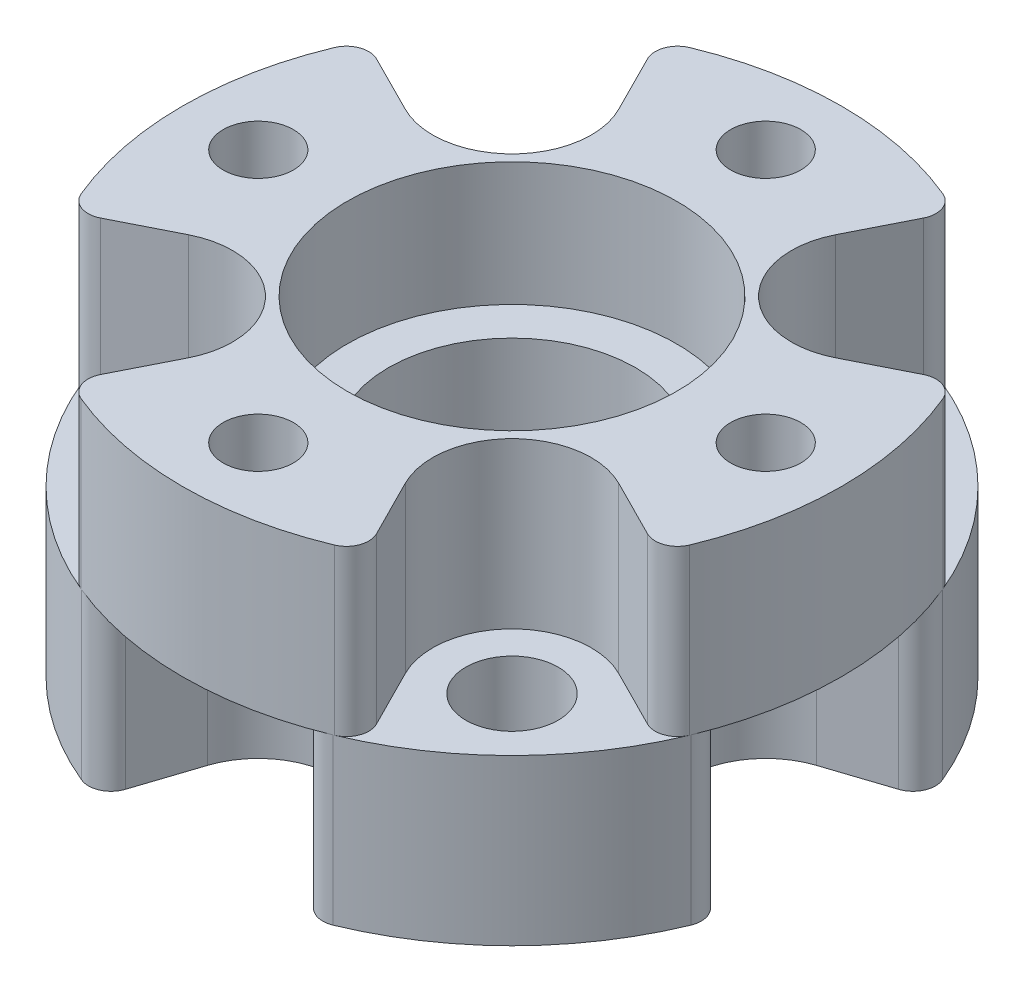
from build123d import *

# Parameters (mm, degrees)
SKETCH1_W                  = 12.7
SKETCH1_H                  = 12.7
CUT_EXTRUDE1_DEPTH         = 6.35
CUT_EXTRUDE2_DEPTH         = 6.35
CUT_EXTRUDE3_DEPTH         = 6.35
CUT_EXTRUDE4_DEPTH         = 6.35
CUT_EXTRUDE5_DEPTH         = 6.35
CUT_EXTRUDE6_DEPTH         = 6.35
CUT_EXTRUDE7_DEPTH         = 6.35
CUT_EXTRUDE8_DEPTH         = 6.35
M3_CLEARANCE_HOLE1_D       = 3.556
M3_CLEARANCE_HOLE1_DEPTH   = 6.35
M2_5_CLEARANCE_HOLE1_D     = 2.7051
M2_5_CLEARANCE_HOLE1_DEPTH = 6.35
FILLET1_R                  = 0.8636


with BuildPart() as part:
    # Sketch1 → Revolve1 (revolve)
    with BuildSketch(Plane.XY):
        with Locations((6.35, 6.35)):
            Rectangle(SKETCH1_W, SKETCH1_H)
    revolve(axis=Axis((0, 12.7, 0), (0, -1, 0)))

    # Sketch2 → Cut-Extrude1 (cut)
    with BuildSketch(Plane(origin=(0, 12.7, 0), x_dir=(-1, 0, 0), z_dir=(0, 1, 0))):
        with BuildLine():
            Line((-5.719139865, -11.339375609), (-4.182577123, -8.292822721))
            ThreePointArc((-4.182577123, -8.292822721), (-4.751006452, -4.751006452), (-8.292822721, -4.182577123))
            Line((-8.292822721, -4.182577123), (-11.339375609, -5.719139865))
            ThreePointArc((-11.339375609, -5.719139865), (-8.980256121, -8.980256121), (-5.719139865, -11.339375609))
        make_face()
    extrude(amount=-CUT_EXTRUDE1_DEPTH, mode=Mode.SUBTRACT)

    # Sketch3 → Cut-Extrude2 (cut)
    with BuildSketch(Plane(origin=(0, 12.7, 0), x_dir=(-1, 0, 0), z_dir=(0, 1, 0))):
        with BuildLine():
            Line((-11.339375609, 5.719139865), (-8.292822721, 4.182577123))
            ThreePointArc((-8.292822721, 4.182577123), (-4.751006452, 4.751006452), (-4.182577123, 8.292822721))
            Line((-4.182577123, 8.292822721), (-5.719139865, 11.339375609))
            ThreePointArc((-5.719139865, 11.339375609), (-8.980256121, 8.980256121), (-11.339375609, 5.719139865))
        make_face()
    extrude(amount=-CUT_EXTRUDE2_DEPTH, mode=Mode.SUBTRACT)

    # Sketch4 → Cut-Extrude3 (cut)
    with BuildSketch(Plane.XZ):
        with BuildLine():
            Line((12.062191969, 3.974106807), (8.821439828, 2.906382535))
            ThreePointArc((8.821439828, 2.906382535), (6.718937759, 0), (8.821439828, -2.906382535))
            Line((8.821439828, -2.906382535), (12.062191969, -3.974106807))
            ThreePointArc((12.062191969, -3.974106807), (12.7, 0), (12.062191969, 3.974106807))
        make_face()
    extrude(amount=-CUT_EXTRUDE3_DEPTH, mode=Mode.SUBTRACT)

    # Sketch5 → Cut-Extrude4 (cut)
    with BuildSketch(Plane(origin=(0, 12.7, 0), x_dir=(-1, 0, 0), z_dir=(0, 1, 0))):
        with BuildLine():
            Line((5.719139865, 11.339375609), (4.182577123, 8.292822721))
            ThreePointArc((4.182577123, 8.292822721), (4.751006452, 4.751006452), (8.292822721, 4.182577123))
            Line((8.292822721, 4.182577123), (11.339375609, 5.719139865))
            ThreePointArc((11.339375609, 5.719139865), (8.980256121, 8.980256121), (5.719139865, 11.339375609))
        make_face()
    extrude(amount=-CUT_EXTRUDE4_DEPTH, mode=Mode.SUBTRACT)

    # Sketch6 → Cut-Extrude5 (cut)
    with BuildSketch(Plane(origin=(0, 12.7, 0), x_dir=(-1, 0, 0), z_dir=(0, 1, 0))):
        with BuildLine():
            Line((11.339375609, -5.719139865), (8.292822721, -4.182577123))
            ThreePointArc((8.292822721, -4.182577123), (4.751006452, -4.751006452), (4.182577123, -8.292822721))
            Line((4.182577123, -8.292822721), (5.719139865, -11.339375609))
            ThreePointArc((5.719139865, -11.339375609), (8.980256121, -8.980256121), (11.339375609, -5.719139865))
        make_face()
    extrude(amount=-CUT_EXTRUDE5_DEPTH, mode=Mode.SUBTRACT)

    # Sketch7 → Cut-Extrude6 (cut)
    with BuildSketch(Plane.XZ):
        with BuildLine():
            Line((3.974106807, -12.062191969), (2.906382535, -8.821439828))
            ThreePointArc((2.906382535, -8.821439828), (0, -6.718937759), (-2.906382535, -8.821439828))
            Line((-2.906382535, -8.821439828), (-3.974106807, -12.062191969))
            ThreePointArc((-3.974106807, -12.062191969), (0, -12.7), (3.974106807, -12.062191969))
        make_face()
    extrude(amount=-CUT_EXTRUDE6_DEPTH, mode=Mode.SUBTRACT)

    # Sketch8 → Cut-Extrude7 (cut)
    with BuildSketch(Plane.XZ):
        with BuildLine():
            Line((-12.062191969, -3.974106807), (-8.821439828, -2.906382535))
            ThreePointArc((-8.821439828, -2.906382535), (-6.718937759, 0), (-8.821439828, 2.906382535))
            Line((-8.821439828, 2.906382535), (-12.062191969, 3.974106807))
            ThreePointArc((-12.062191969, 3.974106807), (-12.7, 0), (-12.062191969, -3.974106807))
        make_face()
    extrude(amount=-CUT_EXTRUDE7_DEPTH, mode=Mode.SUBTRACT)

    # Sketch9 → Cut-Extrude8 (cut)
    with BuildSketch(Plane.XZ):
        with BuildLine():
            Line((-3.974106807, 12.062191969), (-2.906382535, 8.821439828))
            ThreePointArc((-2.906382535, 8.821439828), (0, 6.718937759), (2.906382535, 8.821439828))
            Line((2.906382535, 8.821439828), (3.974106807, 12.062191969))
            ThreePointArc((3.974106807, 12.062191969), (0, 12.7), (-3.974106807, 12.062191969))
        make_face()
    extrude(amount=-CUT_EXTRUDE8_DEPTH, mode=Mode.SUBTRACT)

    # Sketch10 → Cut-Revolve1 (revolve, cut)
    with BuildSketch(Plane(origin=(0, 0, 0), x_dir=(-1, 0, 0), z_dir=(0, 0, -1))):
        Polygon((-6.35, 0), (0, 0), (0, 12.7), (-6.35, 12.7), (-6.35, 7.9375), (-4.7625, 7.9375), (-4.7625, 4.7625), (-6.35, 4.7625), align=None)
    revolve(axis=Axis((0, 0, 0), (0, 1, 0)), mode=Mode.SUBTRACT)

    # M3 Clearance Hole1
    with Locations(Plane(origin=(0, 6.35, 0), x_dir=(1, 0, 0), z_dir=(0, 1, 0))):
        with Locations((6.914797213, 6.914797213), (-6.914797213, 6.914797213), (-6.914797213, -6.914797213), (6.914797213, -6.914797213)):
            Hole(M3_CLEARANCE_HOLE1_D / 2, depth=M3_CLEARANCE_HOLE1_DEPTH)

    # M2.5 Clearance Hole1
    with Locations(Plane(origin=(0, 6.35, 0), x_dir=(-1, 0, 0), z_dir=(0, -1, 0))):
        with Locations((-9.779, 0), (0, 9.779), (9.779, 0), (0, -9.779)):
            Hole(M2_5_CLEARANCE_HOLE1_D / 2, depth=M2_5_CLEARANCE_HOLE1_DEPTH)

    # Fillet1
    fillet1_edges = [part.edges().sort_by_distance(p)[0] for p in [
        (-3.974106807, 3.175, 12.062191969),
        (3.974106807, 3.175, 12.062191969),
        (5.719139865, 9.525, -11.339375609),
        (11.339375609, 9.525, -5.719139865),
        (11.339375609, 9.525, 5.719139865),
        (5.719139865, 9.525, 11.339375609),
        (12.062191969, 3.175, 3.974106807),
        (12.062191969, 3.175, -3.974106807),
        (-5.719139865, 9.525, 11.339375609),
        (-11.339375609, 9.525, 5.719139865),
        (-11.339375609, 9.525, -5.719139865),
        (-5.719139865, 9.525, -11.339375609),
        (3.974106807, 3.175, -12.062191969),
        (-3.974106807, 3.175, -12.062191969),
        (-12.062191969, 3.175, -3.974106807),
        (-12.062191969, 3.175, 3.974106807),
    ]]
    fillet(fillet1_edges, radius=FILLET1_R)


solid = part.part
